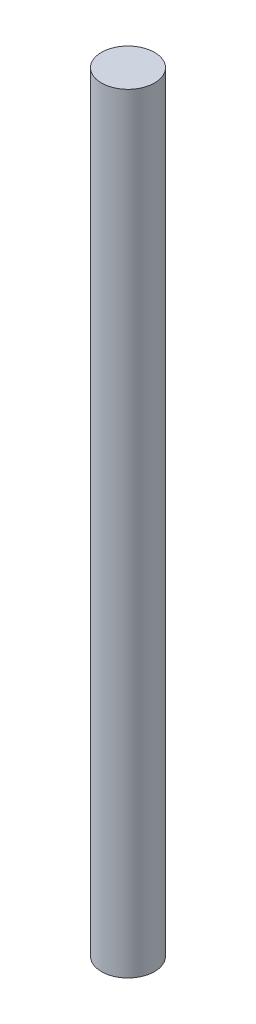
from build123d import *

# Parameters (mm, degrees)
SKETCH1_R           = 1.5
BOSS_EXTRUDE1_DEPTH = 43.5


with BuildPart() as part:
    # Sketch1 → Boss-Extrude1 (new body)
    with BuildSketch(Plane(origin=(0, 0, 0), x_dir=(1, 0, 0), z_dir=(0, 1, 0))):
        Circle(SKETCH1_R)
    extrude(amount=BOSS_EXTRUDE1_DEPTH)


solid = part.part
